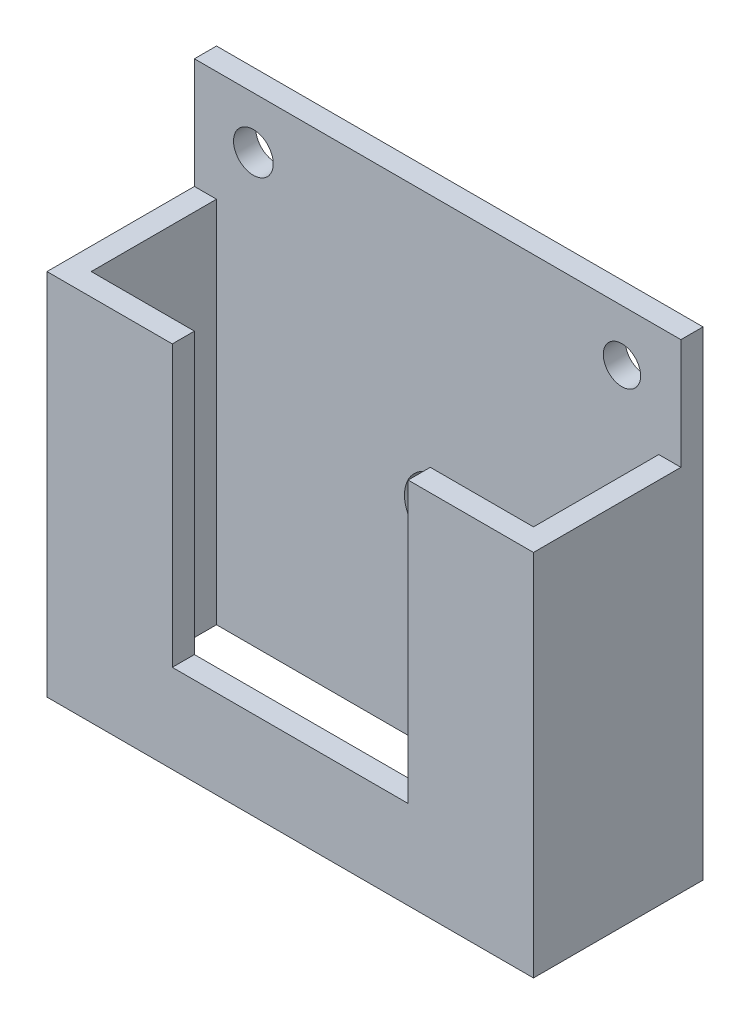
from build123d import *

# Parameters (mm, degrees)
SKETCH1_W           = 23
SKETCH1_H           = 65
BOSS_EXTRUDE1_DEPTH = 66
SKETCH2_W           = 60
SKETCH2_H           = 17
CUT_EXTRUDE1_DEPTH  = 66
CUT_EXTRUDE2_REACH  = 25
SKETCH3_W           = 32
SKETCH3_H           = 53
CUT_EXTRUDE3_REACH  = 25
SKETCH5_R           = 4.5
SKETCH5_R_2         = 2.530586218
SKETCH5_R_3         = 2.69284222
SKETCH6_W           = 17
SKETCH6_H           = 15
CUT_EXTRUDE4_DEPTH  = 20


with BuildPart() as part:
    # Sketch1 → Boss-Extrude1 (new body)
    with BuildSketch(Plane(origin=(0, 0, 0), x_dir=(0, 0, -1), z_dir=(1, 0, 0))):
        with Locations((-11.5, -32.5)):
            Rectangle(SKETCH1_W, SKETCH1_H)
    extrude(amount=-BOSS_EXTRUDE1_DEPTH)

    # Sketch2 → Cut-Extrude1 (cut, through all)
    with BuildSketch(Plane(origin=(0, 0, 0), x_dir=(1, 0, 0), z_dir=(0, 1, 0))):
        with Locations((-33, -11.5)):
            Rectangle(SKETCH2_W, SKETCH2_H)
    extrude(amount=-CUT_EXTRUDE1_DEPTH, mode=Mode.SUBTRACT)

    # Sketch3 → Cut-Extrude2 (cut, up to next)
    with BuildSketch(Plane.XY.offset(23), mode=Mode.PRIVATE) as cut_extrude2_sk1:
        with Locations((-33, -26.5)):
            Rectangle(SKETCH3_W, SKETCH3_H)
    cut_extrude2_tool1 = extrude(cut_extrude2_sk1.sketch, amount=-CUT_EXTRUDE2_REACH, mode=Mode.PRIVATE) & part.part
    add(cut_extrude2_tool1.solids().sort_by_distance((-33, -26.5, 23))[0], mode=Mode.SUBTRACT)

    # Sketch5 → Cut-Extrude3 (cut, up to next)
    with BuildSketch(Plane(origin=(0, 0, 0), x_dir=(-1, 0, 0), z_dir=(0, 0, -1)), mode=Mode.PRIVATE) as cut_extrude3_sk1:
        with Locations((33, -37)):
            Circle(SKETCH5_R)
    cut_extrude3_tool1 = extrude(cut_extrude3_sk1.sketch, amount=-CUT_EXTRUDE3_REACH, mode=Mode.PRIVATE) & part.part
    add(cut_extrude3_tool1.solids().sort_by_distance((-33, -37, 0))[0], mode=Mode.SUBTRACT)
    # Sketch5 → Cut-Extrude3 (cut, up to next)
    with BuildSketch(Plane(origin=(0, 0, 0), x_dir=(-1, 0, 0), z_dir=(0, 0, -1)), mode=Mode.PRIVATE) as cut_extrude3_sk2:
        with Locations((8, -7)):
            Circle(SKETCH5_R_2)
    cut_extrude3_tool2 = extrude(cut_extrude3_sk2.sketch, amount=-CUT_EXTRUDE3_REACH, mode=Mode.PRIVATE) & part.part
    add(cut_extrude3_tool2.solids().sort_by_distance((-8, -7, 0))[0], mode=Mode.SUBTRACT)
    # Sketch5 → Cut-Extrude3 (cut, up to next)
    with BuildSketch(Plane(origin=(0, 0, 0), x_dir=(-1, 0, 0), z_dir=(0, 0, -1)), mode=Mode.PRIVATE) as cut_extrude3_sk3:
        with Locations((58, -7)):
            Circle(SKETCH5_R_3)
    cut_extrude3_tool3 = extrude(cut_extrude3_sk3.sketch, amount=-CUT_EXTRUDE3_REACH, mode=Mode.PRIVATE) & part.part
    add(cut_extrude3_tool3.solids().sort_by_distance((-58, -7, 0))[0], mode=Mode.SUBTRACT)

    # Sketch6 → Cut-Extrude4 (cut)
    with BuildSketch(Plane.XY.offset(23)):
        with Locations((-57.5, -7.5)):
            Rectangle(SKETCH6_W, SKETCH6_H)
        with Locations((-8.5, -7.5)):
            Rectangle(SKETCH6_W, SKETCH6_H)
    extrude(amount=-CUT_EXTRUDE4_DEPTH, mode=Mode.SUBTRACT)


solid = part.part
